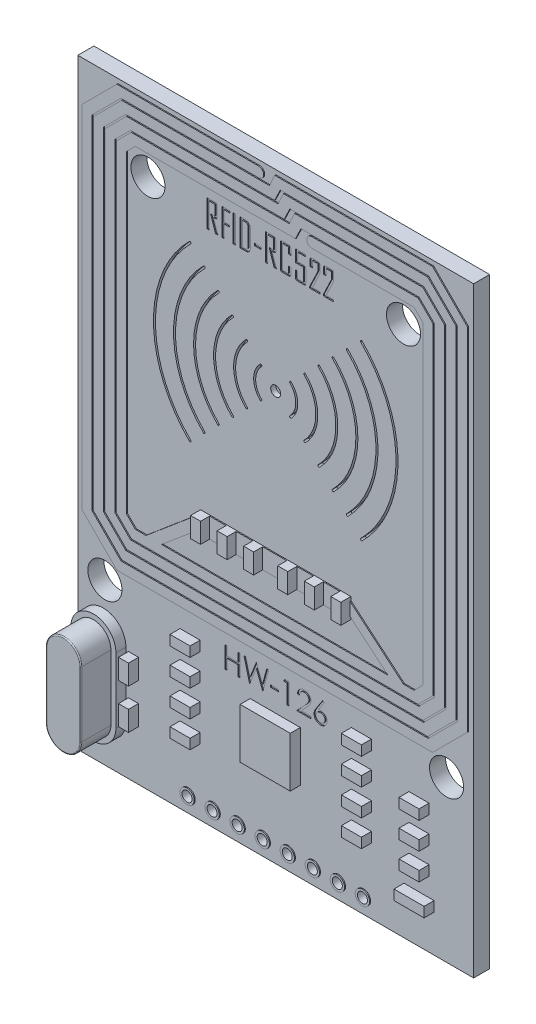
from build123d import *

# Parameters (mm, degrees)
CROQUIS1_W              = 39.5
CROQUIS1_H              = 60
CROQUIS1_R              = 1.7
SALIENTE_EXTRUIR1_DEPTH = 1.6
SALIENTE_EXTRUIR2_DEPTH = 1
SALIENTE_EXTRUIR3_DEPTH = 3
REDONDEO1_R             = 0.1
SALIENTE_EXTRUIR4_DEPTH = 0.1
CROQUIS5_R              = 0.5
CORTAR_EXTRUIR1_DEPTH   = 0.5
CROQUIS7_W              = 1
CROQUIS7_H              = 2
SALIENTE_EXTRUIR5_DEPTH = 1
CROQUIS8_W              = 5
CROQUIS8_H              = 5
CROQUIS8_W_2            = 2
CROQUIS8_H_2            = 1
CROQUIS8_W_3            = 1
CROQUIS8_H_3            = 2
CROQUIS8_W_4            = 3
SALIENTE_EXTRUIR6_DEPTH = 1
CROQUIS9_R              = 0.5
CORTAR_EXTRUIR3_DEPTH   = 2.6
CROQUIS10_R             = 0.717542526
CROQUIS10_R_2           = 0.5
SALIENTE_EXTRUIR7_DEPTH = 0.1
MATRIZL3_COUNT          = 8
MATRIZL3_PITCH          = 2.5
CROQUIS11_W             = 0.227355548
CROQUIS11_H             = 2.695787218
CROQUIS11_W_2           = 0.649587282
CROQUIS11_H_2           = 0.227355549
CORTAR_EXTRUIR4_DEPTH   = 0.1
CROQUIS12_W             = 0.814102565
CROQUIS12_H             = 0.217094017
CORTAR_EXTRUIR5_DEPTH   = 0.1


with BuildPart() as part:
    # Croquis1 → Saliente-Extruir1 (new body)
    with BuildSketch(Plane.XY):
        Rectangle(CROQUIS1_W, CROQUIS1_H)
        with Locations((-12.75, 23)):
            Circle(CROQUIS1_R, mode=Mode.SUBTRACT)
        with Locations((12.75, 23)):
            Circle(CROQUIS1_R, mode=Mode.SUBTRACT)
        with Locations((-17.05, -14)):
            Circle(CROQUIS1_R, mode=Mode.SUBTRACT)
        with Locations((17.05, -14)):
            Circle(CROQUIS1_R, mode=Mode.SUBTRACT)
    extrude(amount=SALIENTE_EXTRUIR1_DEPTH)

    # Croquis2 → Saliente-Extruir2 (add)
    with BuildSketch(Plane.XY.offset(1.6)):
        with BuildLine():
            Line((-19.45, -25.25), (-19.45, -18.75))
            ThreePointArc((-19.45, -18.75), (-17.2, -16.5), (-14.95, -18.75))
            Line((-14.95, -18.75), (-14.95, -25.25))
            ThreePointArc((-14.95, -25.25), (-17.2, -27.5), (-19.45, -25.25))
        make_face()
    extrude(amount=SALIENTE_EXTRUIR2_DEPTH)

    # Croquis3 → Saliente-Extruir3 (add)
    with BuildSketch(Plane.XY.offset(2.6)):
        with BuildLine():
            Line((-18.95, -18.75), (-18.95, -25.25))
            ThreePointArc((-18.95, -25.25), (-17.2, -27), (-15.45, -25.25))
            Line((-15.45, -25.25), (-15.45, -18.75))
            ThreePointArc((-15.45, -18.75), (-17.2, -17), (-18.95, -18.75))
        make_face()
    extrude(amount=SALIENTE_EXTRUIR3_DEPTH)

    # Redondeo1
    redondeo1_edges = [part.edges().sort_by_distance(p)[0] for p in [
        (-15.45, -22, 5.6),
        (-17.2, -17, 5.6),
        (-18.95, -22, 5.6),
        (-17.2, -27, 5.6),
    ]]
    fillet(redondeo1_edges, radius=REDONDEO1_R)

    # Croquis4 → Saliente-Extruir4 (add)
    with BuildSketch(Plane.XY.offset(1.6)):
        with BuildLine():
            Line((-19.25, 26.047780476), (-19.25, -8.952219524))
            Line((-19.25, -8.952219524), (-15.75, -12.452219524))
            Line((-15.75, -12.452219524), (15.75, -12.452219524))
            Line((15.75, -12.452219524), (19.25, -8.952219524))
            Line((19.25, -8.952219524), (19.25, 26.047780476))
            Line((19.25, 26.047780476), (15.75, 29.547780476))
            Line((15.75, 29.547780476), (0, 29.547780476))
            Line((0, 29.547780476), (-0.534883721, 28.397780476))
            Line((-0.534883721, 28.397780476), (-15.273654403, 28.397780476))
            Line((-15.273654403, 28.397780476), (-18.1, 25.571434879))
            Line((-18.1, 25.571434879), (-18.1, -8.475873927))
            Line((-18.1, -8.475873927), (-15.273654403, -11.302219524))
            Line((-15.273654403, -11.302219524), (15.273654403, -11.302219524))
            Line((15.273654403, -11.302219524), (18.1, -8.475873927))
            Line((18.1, -8.475873927), (18.1, 25.571434879))
            Line((18.1, 25.571434879), (15.273654403, 28.397780476))
            Line((15.273654403, 28.397780476), (0.882271335, 28.397780476))
            Line((0.882271335, 28.397780476), (0.32962331, 27.247780476))
            Line((0.32962331, 27.247780476), (-14.797308807, 27.247780476))
            Line((-14.797308807, 27.247780476), (-16.95, 25.095089283))
            Line((-16.95, 25.095089283), (-16.95, -7.999528331))
            Line((-16.95, -7.999528331), (-14.797308807, -10.152219524))
            Line((-14.797308807, -10.152219524), (14.797308807, -10.152219524))
            Line((14.797308807, -10.152219524), (16.95, -7.999528331))
            Line((16.95, -7.999528331), (16.95, 25.095089283))
            Line((16.95, 25.095089283), (14.797308807, 27.247780476))
            Line((14.797308807, 27.247780476), (1.994267695, 27.247780476))
            Line((1.994267695, 27.247780476), (1.43910124, 26.097780476))
            Line((1.43910124, 26.097780476), (-14.32096321, 26.097780476))
            Line((-14.32096321, 26.097780476), (-15.8, 24.618743686))
            Line((-15.8, 24.618743686), (-15.8, -7.523182734))
            Line((-15.8, -7.523182734), (-14.32096321, -9.002219524))
            Line((-14.32096321, -9.002219524), (14.32096321, -9.002219524))
            Line((14.32096321, -9.002219524), (15.8, -7.523182734))
            Line((15.8, -7.523182734), (15.8, 24.618743686))
            Line((15.8, 24.618743686), (14.32096321, 26.097780476))
            Line((14.32096321, 26.097780476), (3.697336559, 26.097780476))
            ThreePointArc((3.697336559, 26.097780476), (3.197336559, 25.597780476), (3.697336559, 25.097780476))
            Line((3.697336559, 25.097780476), (13.906749647, 25.097780476))
            Line((13.906749647, 25.097780476), (14.8, 24.204530123))
            Line((14.8, 24.204530123), (14.8, -7.108969171))
            Line((14.8, -7.108969171), (13.906749647, -8.002219524))
            Line((13.906749647, -8.002219524), (12.844513319, -8.002219524))
            Line((12.844513319, -8.002219524), (7.5, -3.498354667))
            Line((7.5, -3.498354667), (7.5, -3.152219524))
            Line((7.5, -3.152219524), (-7.5, -3.152219524))
            Line((-7.5, -3.152219524), (-7.5, -3.498354667))
            Line((-7.5, -3.498354667), (-12.844513319, -8.002219524))
            Line((-12.844513319, -8.002219524), (-13.906749647, -8.002219524))
            Line((-13.906749647, -8.002219524), (-14.8, -7.108969171))
            Line((-14.8, -7.108969171), (-14.8, 24.204530123))
            Line((-14.8, 24.204530123), (-13.906749647, 25.097780476))
            Line((-13.906749647, 25.097780476), (2.066776044, 25.097780476))
            Line((2.066776044, 25.097780476), (2.621942499, 26.247780476))
            Line((2.621942499, 26.247780476), (14.383095244, 26.247780476))
            Line((14.383095244, 26.247780476), (15.95, 24.68087572))
            Line((15.95, 24.68087572), (15.95, -7.585314768))
            Line((15.95, -7.585314768), (14.383095244, -9.152219524))
            Line((14.383095244, -9.152219524), (-14.383095244, -9.152219524))
            Line((-14.383095244, -9.152219524), (-15.95, -7.585314768))
            Line((-15.95, -7.585314768), (-15.95, 24.68087572))
            Line((-15.95, 24.68087572), (-14.383095244, 26.247780476))
            Line((-14.383095244, 26.247780476), (0.95853774, 26.247780476))
            Line((0.95853774, 26.247780476), (1.511185765, 27.397780476))
            Line((1.511185765, 27.397780476), (14.859440841, 27.397780476))
            Line((14.859440841, 27.397780476), (17.1, 25.157221317))
            Line((17.1, 25.157221317), (17.1, -8.061660365))
            Line((17.1, -8.061660365), (14.859440841, -10.302219524))
            Line((14.859440841, -10.302219524), (-14.859440841, -10.302219524))
            Line((-14.859440841, -10.302219524), (-17.1, -8.061660365))
            Line((-17.1, -8.061660365), (-17.1, 25.157221317))
            Line((-17.1, 25.157221317), (-14.859440841, 27.397780476))
            Line((-14.859440841, 27.397780476), (0, 27.397780476))
            Line((0, 27.397780476), (0.552648025, 28.547780476))
            Line((0.552648025, 28.547780476), (15.335786438, 28.547780476))
            Line((15.335786438, 28.547780476), (18.25, 25.633566914))
            Line((18.25, 25.633566914), (18.25, -8.538005962))
            Line((18.25, -8.538005962), (15.335786438, -11.452219524))
            Line((15.335786438, -11.452219524), (-15.335786438, -11.452219524))
            Line((-15.335786438, -11.452219524), (-18.25, -8.538005962))
            Line((-18.25, -8.538005962), (-18.25, 25.633566914))
            Line((-18.25, 25.633566914), (-15.335786438, 28.547780476))
            Line((-15.335786438, 28.547780476), (-1.600959239, 28.547780476))
            ThreePointArc((-1.600959239, 28.547780476), (-1.100959239, 29.047780476), (-1.600959239, 29.547780476))
            Line((-1.600959239, 29.547780476), (-15.75, 29.547780476))
            Line((-15.75, 29.547780476), (-19.25, 26.047780476))
        make_face()
        Polygon((-11.292695249, -8.002219524), (-7.5, -4.806084381), (-7.5, -5.152219524), (7.5, -5.152219524), (7.5, -4.806084381), (11.292695249, -8.002219524), align=None, mode=Mode.SUBTRACT)
    extrude(amount=SALIENTE_EXTRUIR4_DEPTH)

    # Croquis5 → Cortar-Extruir1 (cut)
    with BuildSketch(Plane.XY.offset(1.6)):
        with Locations((0, 10.847780476)):
            Circle(CROQUIS5_R)
        with BuildLine():
            ThreePointArc((-1.414213562, 12.261994038), (-2, 10.847780476), (-1.414213562, 9.433566914))
            ThreePointArc((-1.414213562, 9.433566914), (-1.414213562, 9.292145557), (-1.555634919, 9.292145557))
            ThreePointArc((-1.555634919, 9.292145557), (-2.2, 10.847780476), (-1.555634919, 12.403415395))
            ThreePointArc((-1.555634919, 12.403415395), (-1.414213562, 12.403415395), (-1.414213562, 12.261994038))
        make_face()
        with BuildLine():
            ThreePointArc((-2.828427125, 13.676207601), (-4, 10.847780476), (-2.828427125, 8.019353351))
            ThreePointArc((-2.828427125, 8.019353351), (-2.828427125, 7.877931995), (-2.969848481, 7.877931995))
            ThreePointArc((-2.969848481, 7.877931995), (-4.2, 10.847780476), (-2.969848481, 13.817628957))
            ThreePointArc((-2.969848481, 13.817628957), (-2.828427125, 13.817628957), (-2.828427125, 13.676207601))
        make_face()
        with BuildLine():
            ThreePointArc((-4.242640687, 15.090421163), (-6, 10.847780476), (-4.242640687, 6.605139789))
            ThreePointArc((-4.242640687, 6.605139789), (-4.242640687, 6.463718433), (-4.384062043, 6.463718433))
            ThreePointArc((-4.384062043, 6.463718433), (-6.2, 10.847780476), (-4.384062043, 15.231842519))
            ThreePointArc((-4.384062043, 15.231842519), (-4.242640687, 15.231842519), (-4.242640687, 15.090421163))
        make_face()
        with BuildLine():
            ThreePointArc((-5.656854249, 16.504634725), (-8, 10.847780476), (-5.656854249, 5.190926227))
            ThreePointArc((-5.656854249, 5.190926227), (-5.656854249, 5.04950487), (-5.798275606, 5.04950487))
            ThreePointArc((-5.798275606, 5.04950487), (-8.2, 10.847780476), (-5.798275606, 16.646056082))
            ThreePointArc((-5.798275606, 16.646056082), (-5.656854249, 16.646056082), (-5.656854249, 16.504634725))
        make_face()
        with BuildLine():
            ThreePointArc((-7.071067812, 17.918848288), (-10, 10.847780476), (-7.071067812, 3.776712664))
            ThreePointArc((-7.071067812, 3.776712664), (-7.071067812, 3.635291308), (-7.212489168, 3.635291308))
            ThreePointArc((-7.212489168, 3.635291308), (-10.2, 10.847780476), (-7.212489168, 18.060269644))
            ThreePointArc((-7.212489168, 18.060269644), (-7.071067812, 18.060269644), (-7.071067812, 17.918848288))
        make_face()
        with BuildLine():
            ThreePointArc((-8.485281374, 19.33306185), (-12, 10.847780476), (-8.485281374, 2.362499102))
            ThreePointArc((-8.485281374, 2.362499102), (-8.485281374, 2.221077746), (-8.62670273, 2.221077746))
            ThreePointArc((-8.62670273, 2.221077746), (-12.2, 10.847780476), (-8.62670273, 19.474483206))
            ThreePointArc((-8.62670273, 19.474483206), (-8.485281374, 19.474483206), (-8.485281374, 19.33306185))
        make_face()
        with BuildLine():
            ThreePointArc((2.828427125, 13.676207601), (2.828427125, 13.817628957), (2.969848481, 13.817628957))
            ThreePointArc((2.969848481, 13.817628957), (4.2, 10.847780476), (2.969848481, 7.877931995))
            ThreePointArc((2.969848481, 7.877931995), (2.828427125, 7.877931995), (2.828427125, 8.019353351))
            ThreePointArc((2.828427125, 8.019353351), (4, 10.847780476), (2.828427125, 13.676207601))
        make_face()
        with BuildLine():
            ThreePointArc((4.242640687, 15.090421163), (4.242640687, 15.231842519), (4.384062043, 15.231842519))
            ThreePointArc((4.384062043, 15.231842519), (6.2, 10.847780476), (4.384062043, 6.463718433))
            ThreePointArc((4.384062043, 6.463718433), (4.242640687, 6.463718433), (4.242640687, 6.605139789))
            ThreePointArc((4.242640687, 6.605139789), (6, 10.847780476), (4.242640687, 15.090421163))
        make_face()
        with BuildLine():
            ThreePointArc((1.414213562, 12.261994038), (1.414213562, 12.403415395), (1.555634919, 12.403415395))
            ThreePointArc((1.555634919, 12.403415395), (2.2, 10.847780476), (1.555634919, 9.292145557))
            ThreePointArc((1.555634919, 9.292145557), (1.414213562, 9.292145557), (1.414213562, 9.433566914))
            ThreePointArc((1.414213562, 9.433566914), (2, 10.847780476), (1.414213562, 12.261994038))
        make_face()
        with BuildLine():
            ThreePointArc((5.656854249, 16.504634725), (5.656854249, 16.646056082), (5.798275606, 16.646056082))
            ThreePointArc((5.798275606, 16.646056082), (8.2, 10.847780476), (5.798275606, 5.04950487))
            ThreePointArc((5.798275606, 5.04950487), (5.656854249, 5.04950487), (5.656854249, 5.190926227))
            ThreePointArc((5.656854249, 5.190926227), (8, 10.847780476), (5.656854249, 16.504634725))
        make_face()
        with BuildLine():
            ThreePointArc((7.071067812, 17.918848288), (7.071067812, 18.060269644), (7.212489168, 18.060269644))
            ThreePointArc((7.212489168, 18.060269644), (10.2, 10.847780476), (7.212489168, 3.635291308))
            ThreePointArc((7.212489168, 3.635291308), (7.071067812, 3.635291308), (7.071067812, 3.776712664))
            ThreePointArc((7.071067812, 3.776712664), (10, 10.847780476), (7.071067812, 17.918848288))
        make_face()
        with BuildLine():
            ThreePointArc((8.62670273, 19.474483206), (8.485281374, 19.474483206), (8.485281374, 19.33306185))
            ThreePointArc((8.485281374, 19.33306185), (12, 10.847780476), (8.485281374, 2.362499102))
            ThreePointArc((8.485281374, 2.362499102), (8.485281374, 2.221077746), (8.62670273, 2.221077746))
            ThreePointArc((8.62670273, 2.221077746), (12.2, 10.847780476), (8.62670273, 19.474483206))
        make_face()
    extrude(amount=-CORTAR_EXTRUIR1_DEPTH, mode=Mode.SUBTRACT)

    # Croquis7 → Saliente-Extruir5 (add)
    with BuildSketch(Plane.XY.offset(1.6)):
        with Locations((-7, -4.152219524)):
            Rectangle(CROQUIS7_W, CROQUIS7_H)
        with Locations((-4.35, -4.152219524)):
            Rectangle(CROQUIS7_W, CROQUIS7_H)
        with Locations((-1.7, -4.152219524)):
            Rectangle(CROQUIS7_W, CROQUIS7_H)
        with Locations((1.7, -4.152219524)):
            Rectangle(CROQUIS7_W, CROQUIS7_H)
        with Locations((4.35, -4.152219524)):
            Rectangle(CROQUIS7_W, CROQUIS7_H)
        with Locations((7, -4.152219524)):
            Rectangle(CROQUIS7_W, CROQUIS7_H)
    extrude(amount=SALIENTE_EXTRUIR5_DEPTH)

    # Croquis8 → Saliente-Extruir6 (add)
    with BuildSketch(Plane.XY.offset(1.6)):
        with Locations((-0.051147358, -19.5)):
            Rectangle(CROQUIS8_W, CROQUIS8_H)
        with Locations((-8.551147358, -14.952219524)):
            Rectangle(CROQUIS8_W_2, CROQUIS8_H_2)
        with Locations((-8.551147358, -17.612219524)):
            Rectangle(CROQUIS8_W_2, CROQUIS8_H_2)
        with Locations((-8.551147358, -20.272219524)):
            Rectangle(CROQUIS8_W_2, CROQUIS8_H_2)
        with Locations((-8.551147358, -22.932219524)):
            Rectangle(CROQUIS8_W_2, CROQUIS8_H_2)
        with Locations((8.551147358, -22.932219524)):
            Rectangle(CROQUIS8_W_2, CROQUIS8_H_2)
        with Locations((8.551147358, -20.272219524)):
            Rectangle(CROQUIS8_W_2, CROQUIS8_H_2)
        with Locations((8.551147358, -17.612219524)):
            Rectangle(CROQUIS8_W_2, CROQUIS8_H_2)
        with Locations((8.551147358, -14.952219524)):
            Rectangle(CROQUIS8_W_2, CROQUIS8_H_2)
        with Locations((-14.193547231, -24.003996479)):
            Rectangle(CROQUIS8_W_3, CROQUIS8_H_3)
        with Locations((-14.193547231, -20.003996479)):
            Rectangle(CROQUIS8_W_3, CROQUIS8_H_3)
        with Locations((14.301080086, -20.272219524)):
            Rectangle(CROQUIS8_W_2, CROQUIS8_H_2)
        with Locations((14.301080086, -17.612219524)):
            Rectangle(CROQUIS8_W_2, CROQUIS8_H_2)
        with Locations((14.301080086, -22.932219524)):
            Rectangle(CROQUIS8_W_2, CROQUIS8_H_2)
        with Locations((14.301080086, -25.782053299)):
            Rectangle(CROQUIS8_W_4, CROQUIS8_H_2)
    extrude(amount=SALIENTE_EXTRUIR6_DEPTH)

    # Croquis9 → Cortar-Extruir3 (cut, through all)
    with BuildSketch(Plane.XY.offset(1.6)):
        with Locations((-8.75, -28.5)):
            Circle(CROQUIS9_R)
        with Locations((-6.25, -28.5)):
            Circle(CROQUIS9_R)
        with Locations((-3.75, -28.5)):
            Circle(CROQUIS9_R)
        with Locations((-1.25, -28.5)):
            Circle(CROQUIS9_R)
        with Locations((1.25, -28.5)):
            Circle(CROQUIS9_R)
        with Locations((3.75, -28.5)):
            Circle(CROQUIS9_R)
        with Locations((6.25, -28.5)):
            Circle(CROQUIS9_R)
        with Locations((8.75, -28.5)):
            Circle(CROQUIS9_R)
    extrude(amount=-CORTAR_EXTRUIR3_DEPTH, mode=Mode.SUBTRACT)

    # Croquis10 → Saliente-Extruir7 (add)
    with BuildSketch(Plane.XY.offset(1.6)):
        with Locations((-8.75, -28.5)):
            Circle(CROQUIS10_R)
        with Locations((-8.75, -28.5)):
            Circle(CROQUIS10_R_2, mode=Mode.SUBTRACT)
    saliente_extruir7 = extrude(amount=SALIENTE_EXTRUIR7_DEPTH)

    # MatrizL3: Saliente-Extruir7 ×8
    with Locations(*[(i * MATRIZL3_PITCH, 0, 0) for i in range(1, MATRIZL3_COUNT)]):
        add(saliente_extruir7)

    # Croquis11 → Cortar-Extruir4 (cut)
    with BuildSketch(Plane.XY.offset(1.6)):
        with BuildLine():
            Line((-5.772253363, 21.446606184), (-5.999608911, 21.446606184))
            Line((-5.999608911, 21.446606184), (-6.486799372, 22.892445375))
            Line((-6.486799372, 22.892445375), (-6.456857458, 22.940656931))
            Line((-6.456857458, 22.940656931), (-6.064567639, 22.940656931))
            Line((-6.064567639, 22.940656931), (-6.064567639, 23.947517218))
            Line((-6.064567639, 23.947517218), (-6.649196193, 23.947517218))
            Line((-6.649196193, 23.947517218), (-6.649196193, 21.446606184))
            Line((-6.649196193, 21.446606184), (-6.876551741, 21.446606184))
            Line((-6.876551741, 21.446606184), (-6.876551741, 24.142393402))
            Line((-6.876551741, 24.142393402), (-6.036148196, 24.142393402))
            add(Edge.make_bspline(
                [(-6.036148196, 24.142393402), (-6.022043733, 24.141730622), (-5.994959103, 24.140457892), (-5.956115522, 24.130090376), (-5.921730204, 24.112102711), (-5.892247347, 24.087358146), (-5.867502781, 24.057875289), (-5.849515117, 24.023489971), (-5.839147601, 23.984646389), (-5.837874871, 23.95756176), (-5.837212091, 23.943457297)],
                knots=[0, 0, 0, 0, 4.2271e-05, 8.1173e-05, 0.000119535, 0.000157742, 0.000195948, 0.00023431, 0.000273212, 0.000315483, 0.000315483, 0.000315483, 0.000315483], degree=3))
            Line((-5.837212091, 23.943457297), (-5.837212091, 22.944716852))
            add(Edge.make_bspline(
                [(-5.837212091, 22.944716852), (-5.837743488, 22.929069909), (-5.838747191, 22.899515937), (-5.850286283, 22.858130683), (-5.869049438, 22.822594249), (-5.896555034, 22.794021996), (-5.931009616, 22.771572781), (-5.973316857, 22.756934185), (-6.022494226, 22.747018373), (-6.05791182, 22.746210425), (-6.076747401, 22.745780747)],
                knots=[0, 0, 0, 0, 4.6824e-05, 8.8441e-05, 0.000127728, 0.00016614, 0.000206116, 0.000249952, 0.000299616, 0.00035603, 0.00035603, 0.00035603, 0.00035603], degree=3))
            add(Edge.make_bspline(
                [(-6.076747401, 22.745780747), (-6.086561169, 22.745881634), (-6.109757101, 22.746120091), (-6.145937227, 22.748280465), (-6.181267578, 22.750482288), (-6.203279409, 22.750747569), (-6.212247248, 22.750855648)],
                knots=[0, 0, 0, 0, 2.9439e-05, 6.9582e-05, 0.000108711, 0.000135613, 0.000135613, 0.000135613, 0.000135613], degree=3))
            add(Edge.make_bspline(
                [(-6.212247248, 22.750855648), (-6.138741374, 22.533849081), (-5.991541278, 22.099279903), (-5.84541166, 21.664349593), (-5.772253363, 21.446606184)],
                knots=[0, 0, 0, 0, 0.000687353, 0.001376467, 0.001376467, 0.001376467, 0.001376467], degree=3))
        make_face()
        Polygon((-4.570516892, 23.947517218), (-5.155145445, 23.947517218), (-5.155145445, 22.908177567), (-4.63547562, 22.908177567), (-4.63547562, 22.713301383), (-5.155145445, 22.713301383), (-5.155145445, 21.446606184), (-5.382500994, 21.446606184), (-5.382500994, 24.142393402), (-4.570516892, 24.142393402), align=None)
        with Locations((-4.132045477, 22.794499793)):
            Rectangle(CROQUIS11_W, CROQUIS11_H)
        with BuildLine():
            add(Edge.make_bspline(
                [(-2.524316956, 21.934304135), (-2.524696482, 21.917537148), (-2.525446595, 21.884398092), (-2.531692345, 21.835834682), (-2.541591222, 21.789137194), (-2.556855052, 21.744903974), (-2.574567019, 21.701968808), (-2.598148947, 21.661886536), (-2.624138571, 21.622901949), (-2.655270001, 21.587266801), (-2.689003832, 21.554459587), (-2.724867521, 21.525218214), (-2.763457961, 21.501342365), (-2.803843667, 21.481301072), (-2.846516753, 21.465524152), (-2.891444593, 21.454410172), (-2.938388117, 21.447609119), (-2.970377494, 21.446944213), (-2.986640403, 21.446606184)],
                knots=[0, 0, 0, 0, 5.0283e-05, 9.9381e-05, 0.000146665, 0.000193204, 0.000239584, 0.000285723, 0.000332457, 0.00037996, 0.000427334, 0.000473541, 0.000518459, 0.00056317, 0.000608609, 0.000654643, 0.000701796, 0.000750557, 0.000750557, 0.000750557, 0.000750557], degree=3))
            Line((-2.986640403, 21.446606184), (-3.563656606, 21.446606184))
            Line((-3.563656606, 21.446606184), (-3.563656606, 24.142393402))
            Line((-3.563656606, 24.142393402), (-2.986640403, 24.142393402))
            add(Edge.make_bspline(
                [(-2.986640403, 24.142393402), (-2.970210971, 24.142047489), (-2.937889964, 24.141366988), (-2.890570775, 24.134699464), (-2.845627389, 24.123301612), (-2.802470166, 24.108335742), (-2.76218074, 24.087656541), (-2.723345562, 24.063798083), (-2.68751755, 24.034675736), (-2.654231273, 24.001723372), (-2.623653197, 23.965940585), (-2.59760834, 23.927134011), (-2.57410992, 23.887011559), (-2.556198055, 23.844200693), (-2.541749603, 23.799755047), (-2.531644909, 23.753180516), (-2.525458978, 23.704597419), (-2.524700642, 23.671461069), (-2.524316956, 23.654695451)],
                knots=[0, 0, 0, 0, 4.9268e-05, 9.6924e-05, 0.000142957, 0.000188224, 0.000233615, 0.000278533, 0.00032474, 0.00037175, 0.000418925, 0.000465658, 0.000511798, 0.000558177, 0.000604559, 0.000651843, 0.000700941, 0.000751223, 0.000751223, 0.000751223, 0.000751223], degree=3))
            Line((-2.524316956, 23.654695451), (-2.524316956, 21.934304135))
        make_face()
        with BuildLine():
            Line((-2.751672504, 21.945468917), (-2.751672504, 23.64657561))
            add(Edge.make_bspline(
                [(-2.751672504, 23.64657561), (-2.752343219, 23.668168348), (-2.753628509, 23.709546505), (-2.769168559, 23.76806875), (-2.792822049, 23.820649018), (-2.827389933, 23.865287846), (-2.868701822, 23.902095577), (-2.916999381, 23.928793424), (-2.971072338, 23.944934946), (-3.009195796, 23.946641404), (-3.028762079, 23.947517218)],
                knots=[0, 0, 0, 0, 6.4613e-05, 0.000123818, 0.000180352, 0.000236482, 0.000291861, 0.000345244, 0.000400805, 0.000459386, 0.000459386, 0.000459386, 0.000459386], degree=3))
            Line((-3.028762079, 23.947517218), (-3.336301057, 23.947517218))
            Line((-3.336301057, 23.947517218), (-3.336301057, 21.641482369))
            Line((-3.336301057, 21.641482369), (-3.04144933, 21.641482369))
            add(Edge.make_bspline(
                [(-3.04144933, 21.641482369), (-3.020875455, 21.642370506), (-2.981144247, 21.644085632), (-2.924644065, 21.659772582), (-2.874206759, 21.685515898), (-2.830948005, 21.721610873), (-2.794493462, 21.765855519), (-2.769962669, 21.819614663), (-2.754130513, 21.880116241), (-2.752516478, 21.923029635), (-2.751672504, 21.945468917)],
                knots=[0, 0, 0, 0, 6.1616e-05, 0.000118989, 0.000174371, 0.000230252, 0.000286921, 0.000344806, 0.000406103, 0.000473284, 0.000473284, 0.000473284, 0.000473284], degree=3))
        make_face(mode=Mode.SUBTRACT)
        with Locations((-1.777291582, 22.469706153)):
            Rectangle(CROQUIS11_W_2, CROQUIS11_H_2)
        with BuildLine():
            Line((0.07403217, 21.446606184), (-0.153323378, 21.446606184))
            Line((-0.153323378, 21.446606184), (-0.640513839, 22.892445375))
            Line((-0.640513839, 22.892445375), (-0.610571926, 22.940656931))
            Line((-0.610571926, 22.940656931), (-0.218282106, 22.940656931))
            Line((-0.218282106, 22.940656931), (-0.218282106, 23.947517218))
            Line((-0.218282106, 23.947517218), (-0.80291066, 23.947517218))
            Line((-0.80291066, 23.947517218), (-0.80291066, 21.446606184))
            Line((-0.80291066, 21.446606184), (-1.030266208, 21.446606184))
            Line((-1.030266208, 21.446606184), (-1.030266208, 24.142393402))
            Line((-1.030266208, 24.142393402), (-0.189862663, 24.142393402))
            add(Edge.make_bspline(
                [(-0.189862663, 24.142393402), (-0.1757582, 24.141730622), (-0.148673571, 24.140457892), (-0.109829989, 24.130090376), (-0.075444671, 24.112102711), (-0.045961814, 24.087358146), (-0.021217249, 24.057875289), (-0.003229584, 24.023489971), (0.007137932, 23.984646389), (0.008410662, 23.95756176), (0.009073442, 23.943457297)],
                knots=[0, 0, 0, 0, 4.2271e-05, 8.1173e-05, 0.000119535, 0.000157742, 0.000195948, 0.00023431, 0.000273212, 0.000315483, 0.000315483, 0.000315483, 0.000315483], degree=3))
            Line((0.009073442, 23.943457297), (0.009073442, 22.944716852))
            add(Edge.make_bspline(
                [(0.009073442, 22.944716852), (0.008542045, 22.929069909), (0.007538342, 22.899515937), (-0.00400075, 22.858130683), (-0.022763905, 22.822594249), (-0.050269501, 22.794021996), (-0.084724084, 22.771572781), (-0.127031324, 22.756934185), (-0.176208693, 22.747018373), (-0.211626287, 22.746210425), (-0.230461868, 22.745780747)],
                knots=[0, 0, 0, 0, 4.6824e-05, 8.8441e-05, 0.000127728, 0.00016614, 0.000206116, 0.000249952, 0.000299616, 0.00035603, 0.00035603, 0.00035603, 0.00035603], degree=3))
            add(Edge.make_bspline(
                [(-0.230461868, 22.745780747), (-0.240275636, 22.745881634), (-0.263471568, 22.746120091), (-0.299651694, 22.748280465), (-0.334982045, 22.750482288), (-0.356993876, 22.750747569), (-0.365961715, 22.750855648)],
                knots=[0, 0, 0, 0, 2.9439e-05, 6.9582e-05, 0.000108711, 0.000135613, 0.000135613, 0.000135613, 0.000135613], degree=3))
            add(Edge.make_bspline(
                [(-0.365961715, 22.750855648), (-0.292455841, 22.533849081), (-0.145255745, 22.099279903), (0.000873873, 21.664349593), (0.07403217, 21.446606184)],
                knots=[0, 0, 0, 0, 0.000687353, 0.001376467, 0.001376467, 0.001376467, 0.001376467], degree=3))
        make_face()
        with BuildLine():
            add(Edge.make_bspline(
                [(1.503124189, 21.645542289), (1.502534016, 21.631414446), (1.501398821, 21.604239638), (1.49004687, 21.565744408), (1.472863768, 21.530765577), (1.447647438, 21.501191305), (1.417789046, 21.476432651), (1.3830716, 21.459008842), (1.344707066, 21.44859986), (1.317956728, 21.44728365), (1.304188084, 21.446606184)],
                knots=[0, 0, 0, 0, 4.2271e-05, 8.1308e-05, 0.000119438, 0.000158359, 0.000196959, 0.000235088, 0.00027399, 0.00031525, 0.00031525, 0.00031525, 0.00031525], degree=3))
            Line((1.304188084, 21.446606184), (0.662720644, 21.446606184))
            add(Edge.make_bspline(
                [(0.662720644, 21.446606184), (0.648611481, 21.447258181), (0.621517826, 21.448510202), (0.582812894, 21.459002465), (0.548138363, 21.476458491), (0.518202161, 21.501023806), (0.493636846, 21.530960008), (0.47618082, 21.565634539), (0.465688557, 21.604339471), (0.464436536, 21.631433126), (0.463784539, 21.645542289)],
                knots=[0, 0, 0, 0, 4.2271e-05, 8.1173e-05, 0.000119302, 0.000157902, 0.000196501, 0.00023463, 0.000273532, 0.000315803, 0.000315803, 0.000315803, 0.000315803], degree=3))
            Line((0.463784539, 21.645542289), (0.463784539, 23.943457297))
            add(Edge.make_bspline(
                [(0.463784539, 23.943457297), (0.464434162, 23.957568227), (0.465681624, 23.984665275), (0.476205786, 24.023346465), (0.493485741, 24.057990314), (0.518368486, 24.087522769), (0.548254667, 24.11194932), (0.582669423, 24.130115237), (0.621536689, 24.140451006), (0.648617941, 24.141728263), (0.662720644, 24.142393402)],
                knots=[0, 0, 0, 0, 4.2271e-05, 8.1173e-05, 0.000119302, 0.000157509, 0.000196108, 0.00023447, 0.000273372, 0.000315643, 0.000315643, 0.000315643, 0.000315643], degree=3))
            Line((0.662720644, 24.142393402), (1.304188084, 24.142393402))
            add(Edge.make_bspline(
                [(1.304188084, 24.142393402), (1.317950491, 24.141703257), (1.344688709, 24.140362414), (1.383215112, 24.130108852), (1.417672929, 24.111975725), (1.447482608, 24.087353733), (1.473013322, 24.058186656), (1.490021868, 24.023236185), (1.501405745, 23.984765209), (1.502536384, 23.957586939), (1.503124189, 23.943457297)],
                knots=[0, 0, 0, 0, 4.126e-05, 8.0162e-05, 0.000118523, 0.000157123, 0.000195655, 0.000233784, 0.000272822, 0.000315093, 0.000315093, 0.000315093, 0.000315093], degree=3))
            Line((1.503124189, 23.943457297), (1.503124189, 23.3304093))
            Line((1.503124189, 23.3304093), (1.275768641, 23.3304093))
            Line((1.275768641, 23.3304093), (1.275768641, 23.947517218))
            Line((1.275768641, 23.947517218), (0.691140087, 23.947517218))
            Line((0.691140087, 23.947517218), (0.691140087, 21.641482369))
            Line((0.691140087, 21.641482369), (1.275768641, 21.641482369))
            Line((1.275768641, 21.641482369), (1.275768641, 22.29106965))
            Line((1.275768641, 22.29106965), (1.503124189, 22.29106965))
            Line((1.503124189, 22.29106965), (1.503124189, 21.645542289))
        make_face()
        with BuildLine():
            add(Edge.make_bspline(
                [(2.997174937, 21.645542289), (2.996523215, 21.632106501), (2.995247291, 21.605802278), (2.984225314, 21.56784435), (2.965592448, 21.533378218), (2.940280456, 21.503116706), (2.909828019, 21.478378183), (2.875851648, 21.459407996), (2.837963219, 21.448561793), (2.811669337, 21.44726736), (2.798238832, 21.446606184)],
                knots=[0, 0, 0, 0, 4.0249e-05, 7.8798e-05, 0.000117397, 0.000157034, 0.000196347, 0.0002345, 0.000273049, 0.000313298, 0.000313298, 0.000313298, 0.000313298], degree=3))
            Line((2.798238832, 21.446606184), (2.156771391, 21.446606184))
            add(Edge.make_bspline(
                [(2.156771391, 21.446606184), (2.143166415, 21.447246326), (2.116692595, 21.448491974), (2.078547634, 21.45953127), (2.044264277, 21.478231108), (2.013735182, 21.502994291), (1.988856456, 21.533410516), (1.970875496, 21.567974129), (1.959733192, 21.605788328), (1.958476953, 21.632101785), (1.957835286, 21.645542289)],
                knots=[0, 0, 0, 0, 4.0754e-05, 7.9304e-05, 0.000117903, 0.000157216, 0.000196529, 0.000234891, 0.00027344, 0.000313689, 0.000313689, 0.000313689, 0.000313689], degree=3))
            Line((1.957835286, 21.645542289), (1.957835286, 22.323549014))
            Line((1.957835286, 22.323549014), (2.185190835, 22.323549014))
            Line((2.185190835, 22.323549014), (2.185190835, 21.641482369))
            Line((2.185190835, 21.641482369), (2.769819388, 21.641482369))
            Line((2.769819388, 21.641482369), (2.769819388, 22.940656931))
            Line((2.769819388, 22.940656931), (1.957835286, 22.940656931))
            Line((1.957835286, 22.940656931), (1.99031465, 24.142393402))
            Line((1.99031465, 24.142393402), (2.964695572, 24.142393402))
            Line((2.964695572, 24.142393402), (2.964695572, 23.947517218))
            Line((2.964695572, 23.947517218), (2.214625258, 23.947517218))
            Line((2.214625258, 23.947517218), (2.185190835, 23.135533116))
            Line((2.185190835, 23.135533116), (2.798238832, 23.135533116))
            add(Edge.make_bspline(
                [(2.798238832, 23.135533116), (2.811671102, 23.134850619), (2.837922649, 23.133516773), (2.875515381, 23.123063225), (2.90994856, 23.1060051), (2.940005213, 23.082063593), (2.965865846, 23.053276192), (2.984285064, 23.0192153), (2.995338982, 22.981087024), (2.99654925, 22.954435368), (2.997174937, 22.940656931)],
                knots=[0, 0, 0, 0, 4.0249e-05, 7.8661e-05, 0.000116109, 0.000154788, 0.000193267, 0.00023142, 0.000269969, 0.000311229, 0.000311229, 0.000311229, 0.000311229], degree=3))
            Line((2.997174937, 22.940656931), (2.997174937, 21.645542289))
        make_face()
        with BuildLine():
            Line((4.426266956, 21.446606184), (3.386927305, 21.446606184))
            Line((3.386927305, 21.446606184), (3.386927305, 21.57652364))
            Line((3.386927305, 21.57652364), (4.198911407, 23.280675274))
            Line((4.198911407, 23.280675274), (4.198911407, 23.947517218))
            Line((4.198911407, 23.947517218), (3.646762218, 23.947517218))
            Line((3.646762218, 23.947517218), (3.646762218, 23.3304093))
            Line((3.646762218, 23.3304093), (3.419406669, 23.3304093))
            Line((3.419406669, 23.3304093), (3.419406669, 23.943457297))
            add(Edge.make_bspline(
                [(3.419406669, 23.943457297), (3.420107072, 23.955877415), (3.421493602, 23.980464497), (3.432184812, 24.01636045), (3.449739124, 24.050249461), (3.473981839, 24.081377653), (3.503608657, 24.108255801), (3.537935414, 24.128675028), (3.577052976, 24.140043106), (3.604230668, 24.141590113), (3.618342774, 24.142393402)],
                knots=[0, 0, 0, 0, 3.7217e-05, 7.3675e-05, 0.000111352, 0.000151144, 0.000191393, 0.000230736, 0.000269915, 0.000312231, 0.000312231, 0.000312231, 0.000312231], degree=3))
            Line((3.618342774, 24.142393402), (4.227330851, 24.142393402))
            add(Edge.make_bspline(
                [(4.227330851, 24.142393402), (4.240776244, 24.141781643), (4.267147166, 24.14058178), (4.304947562, 24.128979572), (4.339299306, 24.109670344), (4.369092711, 24.08327953), (4.394449676, 24.05277726), (4.413219015, 24.018783922), (4.424302209, 23.981861291), (4.42560545, 23.95638745), (4.426266956, 23.943457297)],
                knots=[0, 0, 0, 0, 4.0249e-05, 7.8941e-05, 0.00011734, 0.000157634, 0.000197661, 0.000235814, 0.000273389, 0.000312121, 0.000312121, 0.000312121, 0.000312121], degree=3))
            Line((4.426266956, 23.943457297), (4.426266956, 23.352738863))
            add(Edge.make_bspline(
                [(4.426266956, 23.352738863), (4.425341508, 23.334928907), (4.423412961, 23.297814585), (4.411639289, 23.240550062), (4.392134741, 23.179933701), (4.374220741, 23.13943767), (4.364860658, 23.118278454)],
                knots=[0, 0, 0, 0, 5.3441e-05, 0.000111366, 0.000174762, 0.000244132, 0.000244132, 0.000244132, 0.000244132], degree=3))
            Line((4.364860658, 23.118278454), (3.679241582, 21.641482369))
            Line((3.679241582, 21.641482369), (4.426266956, 21.641482369))
            Line((4.426266956, 21.641482369), (4.426266956, 21.446606184))
        make_face()
        with BuildLine():
            Line((5.790400247, 21.446606184), (4.751060596, 21.446606184))
            Line((4.751060596, 21.446606184), (4.751060596, 21.57652364))
            Line((4.751060596, 21.57652364), (5.563044698, 23.280675274))
            Line((5.563044698, 23.280675274), (5.563044698, 23.947517218))
            Line((5.563044698, 23.947517218), (5.010895509, 23.947517218))
            Line((5.010895509, 23.947517218), (5.010895509, 23.3304093))
            Line((5.010895509, 23.3304093), (4.78353996, 23.3304093))
            Line((4.78353996, 23.3304093), (4.78353996, 23.943457297))
            add(Edge.make_bspline(
                [(4.78353996, 23.943457297), (4.784240363, 23.955877415), (4.785626893, 23.980464497), (4.796318103, 24.01636045), (4.813872415, 24.050249461), (4.83811513, 24.081377653), (4.867741948, 24.108255801), (4.902068705, 24.128675028), (4.941186267, 24.140043106), (4.968363959, 24.141590113), (4.982476065, 24.142393402)],
                knots=[0, 0, 0, 0, 3.7217e-05, 7.3675e-05, 0.000111352, 0.000151144, 0.000191393, 0.000230736, 0.000269915, 0.000312231, 0.000312231, 0.000312231, 0.000312231], degree=3))
            Line((4.982476065, 24.142393402), (5.591464142, 24.142393402))
            add(Edge.make_bspline(
                [(5.591464142, 24.142393402), (5.604909535, 24.141781643), (5.631280457, 24.14058178), (5.669080853, 24.128979572), (5.703432597, 24.109670344), (5.733226002, 24.08327953), (5.758582967, 24.05277726), (5.777352306, 24.018783922), (5.7884355, 23.981861291), (5.789738741, 23.95638745), (5.790400247, 23.943457297)],
                knots=[0, 0, 0, 0, 4.0249e-05, 7.8941e-05, 0.00011734, 0.000157634, 0.000197661, 0.000235814, 0.000273389, 0.000312121, 0.000312121, 0.000312121, 0.000312121], degree=3))
            Line((5.790400247, 23.943457297), (5.790400247, 23.352738863))
            add(Edge.make_bspline(
                [(5.790400247, 23.352738863), (5.789474799, 23.334928907), (5.787546252, 23.297814585), (5.77577258, 23.240550062), (5.756268032, 23.179933701), (5.738354032, 23.13943767), (5.728993949, 23.118278454)],
                knots=[0, 0, 0, 0, 5.3441e-05, 0.000111366, 0.000174762, 0.000244132, 0.000244132, 0.000244132, 0.000244132], degree=3))
            Line((5.728993949, 23.118278454), (5.043374873, 21.641482369))
            Line((5.043374873, 21.641482369), (5.790400247, 21.641482369))
            Line((5.790400247, 21.641482369), (5.790400247, 21.446606184))
        make_face()
    extrude(amount=-CORTAR_EXTRUIR4_DEPTH, mode=Mode.SUBTRACT)

    # Croquis12 → Cortar-Extruir5 (cut)
    with BuildSketch(Plane.XY.offset(1.6)):
        Polygon((-5.045366096, -13.599707492), (-4.855408831, -13.599707492), (-4.855408831, -14.468083561), (-3.769938746, -14.468083561), (-3.769938746, -13.599707492), (-3.579981481, -13.599707492), (-3.579981481, -15.716374159), (-3.769938746, -15.716374159), (-3.769938746, -14.685177578), (-4.855408831, -14.685177578), (-4.855408831, -15.716374159), (-5.045366096, -15.716374159), align=None)
        Polygon((-3.172930199, -13.599707492), (-2.976612758, -13.599707492), (-2.562353276, -15.152014517), (-1.9462642, -13.599707492), (-1.918703436, -13.599707492), (-1.314062678, -15.141414223), (-0.897683137, -13.599707492), (-0.703485755, -13.599707492), (-1.274205573, -15.716374159), (-1.301342325, -15.716374159), (-1.938207977, -14.097497289), (-2.58270584, -15.716374159), (-2.609842592, -15.716374159), align=None)
        with Locations((-0.106477208, -14.902271595)):
            Rectangle(CROQUIS12_W, CROQUIS12_H)
        Polygon((0.913271056, -13.599707492), (1.304633904, -13.599707492), (1.304633904, -15.716374159), (1.114676639, -15.716374159), (1.114676639, -13.816801509), (0.789035613, -13.816801509), align=None)
        with BuildLine():
            Line((2.362967237, -14.250989543), (2.173009972, -14.250989543))
            add(Edge.make_bspline(
                [(2.173009972, -14.250989543), (2.174248012, -14.225788578), (2.17667949, -14.176294553), (2.188066122, -14.104132), (2.204358938, -14.035156002), (2.227395199, -13.969920388), (2.256004233, -13.907848347), (2.290312393, -13.849186433), (2.330948674, -13.794158428), (2.377035603, -13.743274461), (2.427090923, -13.696594359), (2.481099753, -13.656283807), (2.537853651, -13.622225025), (2.59718043, -13.593752083), (2.659749438, -13.572379891), (2.72499288, -13.556522042), (2.793197405, -13.546981109), (2.839667324, -13.545955563), (2.863301104, -13.545433988)],
                knots=[0, 0, 0, 0, 7.5645e-05, 0.000148566, 0.000218806, 0.000288002, 0.000355729, 0.000423578, 0.000491507, 0.00056056, 0.000629272, 0.00069652, 0.00076233, 0.000827574, 0.000893548, 0.000960292, 0.001028772, 0.001099644, 0.001099644, 0.001099644, 0.001099644], degree=3))
            add(Edge.make_bspline(
                [(2.863301104, -13.545433988), (2.886510702, -13.54597734), (2.932116731, -13.547045008), (2.998678045, -13.556213821), (3.062043361, -13.57057425), (3.122088819, -13.590722145), (3.178335344, -13.61780606), (3.231205471, -13.650340762), (3.281328628, -13.687968946), (3.326447969, -13.732270062), (3.367879045, -13.779563885), (3.403621838, -13.830054188), (3.434230751, -13.882202375), (3.459744252, -13.936406097), (3.478525822, -13.993175719), (3.492785024, -14.051684742), (3.500844936, -14.112538794), (3.50208193, -14.153727045), (3.502710827, -14.174667428)],
                knots=[0, 0, 0, 0, 6.9601e-05, 0.000136764, 0.000201152, 0.000264307, 0.000326325, 0.000387992, 0.000450323, 0.000513897, 0.000577319, 0.000638734, 0.000699166, 0.000758543, 0.000818077, 0.00087824, 0.000938987, 0.00100181, 0.00100181, 0.00100181, 0.00100181], degree=3))
            add(Edge.make_bspline(
                [(3.502710827, -14.174667428), (3.501686806, -14.204148261), (3.499656734, -14.262592581), (3.482291373, -14.34847776), (3.455169912, -14.431689018), (3.422514367, -14.49865872), (3.389571508, -14.552623738), (3.359885254, -14.597054812), (3.325132725, -14.644894785), (3.28480811, -14.695983461), (3.239745563, -14.750721008), (3.189536921, -14.809074361), (3.133824149, -14.870440621), (3.094721151, -14.912354009), (3.074458957, -14.934072476)],
                knots=[0, 0, 0, 0, 8.8367e-05, 0.000175182, 0.000261801, 0.000350363, 0.00039792, 0.000451428, 0.000510628, 0.000575261, 0.000646653, 0.000723319, 0.000806176, 0.000895284, 0.000895284, 0.000895284, 0.000895284], degree=3))
            Line((3.074458957, -14.934072476), (2.544868279, -15.499280142))
            Line((2.544868279, -15.499280142), (3.529847579, -15.499280142))
            Line((3.529847579, -15.499280142), (3.529847579, -15.716374159))
            Line((3.529847579, -15.716374159), (2.091599716, -15.716374159))
            Line((2.091599716, -15.716374159), (2.912486468, -14.840365879))
            add(Edge.make_bspline(
                [(2.912486468, -14.840365879), (2.932472571, -14.819502617), (2.970861784, -14.779428562), (3.025158866, -14.720922105), (3.073926255, -14.666645002), (3.11747963, -14.616699803), (3.154874179, -14.57035595), (3.188058814, -14.529114392), (3.214647529, -14.491162891), (3.243503982, -14.447172138), (3.271452438, -14.393461832), (3.295468958, -14.327824792), (3.310113176, -14.260256406), (3.31186991, -14.21459565), (3.312753562, -14.191627898)],
                knots=[0, 0, 0, 0, 8.6674e-05, 0.000166483, 0.000239444, 0.000305579, 0.000365245, 0.00041809, 0.000464325, 0.000504196, 0.000575883, 0.000645364, 0.000713388, 0.000782236, 0.000782236, 0.000782236, 0.000782236], degree=3))
            add(Edge.make_bspline(
                [(3.312753562, -14.191627898), (3.312369089, -14.177185338), (3.311611367, -14.148721826), (3.304924093, -14.106989772), (3.294818215, -14.066733908), (3.280337035, -14.02783041), (3.261222483, -13.99067042), (3.237955249, -13.955208706), (3.211109829, -13.920925379), (3.180054538, -13.88878029), (3.145939, -13.859339751), (3.109898668, -13.833259947), (3.071768367, -13.811464866), (3.031708864, -13.793598084), (2.989831842, -13.779582496), (2.946056306, -13.769870879), (2.90050321, -13.763773377), (2.869398192, -13.762948378), (2.853548834, -13.762528005)],
                knots=[0, 0, 0, 0, 4.3301e-05, 8.5338e-05, 0.000126474, 0.000167664, 0.000209573, 0.000251559, 0.000294735, 0.000340017, 0.00038541, 0.000429771, 0.000473265, 0.00051692, 0.000561168, 0.000605503, 0.000651259, 0.000698795, 0.000698795, 0.000698795, 0.000698795], degree=3))
            add(Edge.make_bspline(
                [(2.853548834, -13.762528005), (2.836995997, -13.762960429), (2.804488959, -13.763809639), (2.756761734, -13.769750012), (2.711231764, -13.779998211), (2.667784518, -13.794014581), (2.626346482, -13.811829989), (2.587119179, -13.834019758), (2.55019067, -13.860498347), (2.515491535, -13.890519064), (2.483521414, -13.923942804), (2.455432113, -13.961202163), (2.430888447, -14.001616838), (2.409474292, -14.04507778), (2.392083946, -14.091979352), (2.378795422, -14.142155059), (2.368280519, -14.195387037), (2.364767747, -14.232147541), (2.362967237, -14.250989543)],
                knots=[0, 0, 0, 0, 4.9655e-05, 9.7514e-05, 0.00014401, 0.000189466, 0.000234285, 0.000279095, 0.000324392, 0.000370383, 0.000416572, 0.000462874, 0.000510069, 0.000558235, 0.000608011, 0.000659852, 0.000713821, 0.000770572, 0.000770572, 0.000770572, 0.000770572], degree=3))
        make_face()
        with BuildLine():
            Line((4.696727921, -13.545433988), (4.843011975, -13.660341173))
            Line((4.843011975, -13.660341173), (4.283740474, -14.515572877))
            add(Edge.make_bspline(
                [(4.283740474, -14.515572877), (4.320975832, -14.509637828), (4.393607608, -14.498060844), (4.467126032, -14.496151038), (4.50295455, -14.495220313)],
                knots=[0, 0, 0, 0, 0.000112975, 0.000220371, 0.000220371, 0.000220371, 0.000220371], degree=3))
            add(Edge.make_bspline(
                [(4.50295455, -14.495220313), (4.524467441, -14.495798533), (4.566814926, -14.496936741), (4.628988563, -14.505696023), (4.688732348, -14.519499781), (4.745798657, -14.539621574), (4.800392317, -14.565325378), (4.852826623, -14.596131267), (4.902115934, -14.63362994), (4.948894981, -14.675518747), (4.991365654, -14.721914256), (5.028967364, -14.771142684), (5.060552138, -14.82315274), (5.086178271, -14.877918083), (5.106077888, -14.935354292), (5.120584702, -14.995387881), (5.12915998, -15.058060247), (5.130324443, -15.100682763), (5.130915955, -15.122333694)],
                knots=[0, 0, 0, 0, 6.4518e-05, 0.000127002, 0.00018799, 0.000248202, 0.000308142, 0.000368789, 0.000430271, 0.000493619, 0.000556939, 0.000618676, 0.000679177, 0.000739118, 0.000799729, 0.000861228, 0.000924132, 0.000989074, 0.000989074, 0.000989074, 0.000989074], degree=3))
            add(Edge.make_bspline(
                [(5.130915955, -15.122333694), (5.130055315, -15.151954753), (5.12836178, -15.210241987), (5.111486627, -15.295136472), (5.085264366, -15.376012803), (5.047782718, -15.45157972), (5.001226705, -15.521733655), (4.944453114, -15.583894389), (4.879475385, -15.639332936), (4.806004797, -15.685691939), (4.726936433, -15.723551879), (4.643871178, -15.750745144), (4.557615713, -15.767487052), (4.499071974, -15.76958594), (4.469457622, -15.770647663)],
                knots=[0, 0, 0, 0, 8.8764e-05, 0.000174667, 0.000258605, 0.000343179, 0.00042691, 0.000510366, 0.000594898, 0.00068241, 0.000770222, 0.000857244, 0.00094398, 0.001032769, 0.001032769, 0.001032769, 0.001032769], degree=3))
            add(Edge.make_bspline(
                [(4.469457622, -15.770647663), (4.440975331, -15.769723463), (4.384556901, -15.767892783), (4.301563735, -15.751584811), (4.221818005, -15.72515242), (4.145878427, -15.688737118), (4.075532152, -15.642740208), (4.012597219, -15.58736683), (3.957387432, -15.52380063), (3.911440875, -15.452051467), (3.87499869, -15.374950398), (3.847669545, -15.29455507), (3.831706102, -15.211158414), (3.829475404, -15.154624582), (3.828351852, -15.1261498)],
                knots=[0, 0, 0, 0, 8.5378e-05, 0.000169119, 0.000252654, 0.000336857, 0.000421061, 0.000503987, 0.000587553, 0.000672823, 0.000758739, 0.00084281, 0.000926968, 0.001012372, 0.001012372, 0.001012372, 0.001012372], degree=3))
            add(Edge.make_bspline(
                [(3.828351852, -15.1261498), (3.829066345, -15.104351409), (3.830525203, -15.05984326), (3.840711444, -14.992434062), (3.857079201, -14.923460313), (3.875409683, -14.864947062), (3.894777552, -14.817012713), (3.910895993, -14.778366317), (3.930958362, -14.738596525), (3.952350835, -14.696339612), (3.976999037, -14.652684612), (4.003799453, -14.606901916), (4.033493052, -14.559719646), (4.054309055, -14.527701014), (4.06495041, -14.511332759)],
                knots=[0, 0, 0, 0, 6.5386e-05, 0.000133505, 0.00020406, 0.000277946, 0.000317158, 0.000359137, 0.00040351, 0.00045073, 0.000501221, 0.000553871, 0.000609872, 0.000668443, 0.000668443, 0.000668443, 0.000668443], degree=3))
            Line((4.06495041, -14.511332759), (4.696727921, -13.545433988))
        make_face()
        with BuildLine():
            add(Edge.make_bspline(
                [(4.463097445, -14.71231433), (4.446973135, -14.712784861), (4.415477674, -14.713703945), (4.36926938, -14.719041121), (4.325537081, -14.729091699), (4.283701385, -14.74189229), (4.244544441, -14.759492712), (4.207781667, -14.780872133), (4.173270897, -14.806043036), (4.141373606, -14.834648825), (4.112454096, -14.865968255), (4.087549317, -14.899514109), (4.066066722, -14.934477936), (4.048600098, -14.971151873), (4.034998957, -15.009521899), (4.025160539, -15.04941154), (4.019685175, -15.091088287), (4.018774264, -15.119350324), (4.018309117, -15.133782011)],
                knots=[0, 0, 0, 0, 4.8384e-05, 9.4508e-05, 0.000139256, 0.000182839, 0.000225546, 0.000267727, 0.000310217, 0.000353458, 0.00039607, 0.000437878, 0.000478601, 0.000518998, 0.000559499, 0.000600532, 0.000642029, 0.00068533, 0.00068533, 0.00068533, 0.00068533], degree=3))
            add(Edge.make_bspline(
                [(4.018309117, -15.133782011), (4.018687917, -15.148084618), (4.019430686, -15.176129901), (4.026175185, -15.217458834), (4.036477353, -15.257230945), (4.051802259, -15.295241197), (4.07008233, -15.332068971), (4.09421555, -15.36638031), (4.120956177, -15.400259114), (4.152920223, -15.431102861), (4.187224352, -15.45980282), (4.223873651, -15.484888497), (4.262070388, -15.506349183), (4.302330248, -15.523168275), (4.344082033, -15.536971534), (4.387673606, -15.546684905), (4.433135285, -15.552176461), (4.463930934, -15.553088559), (4.479633904, -15.553553646)],
                knots=[0, 0, 0, 0, 4.2878e-05, 8.4077e-05, 0.000125319, 0.00016587, 0.00020683, 0.000248344, 0.000291454, 0.000336128, 0.000381297, 0.000425518, 0.000469173, 0.000512489, 0.000556201, 0.00060095, 0.000646232, 0.000693345, 0.000693345, 0.000693345, 0.000693345], degree=3))
            add(Edge.make_bspline(
                [(4.479633904, -15.553553646), (4.495336848, -15.553088523), (4.526132446, -15.552176353), (4.571594491, -15.546685315), (4.615184712, -15.536970028), (4.65694141, -15.523173734), (4.697183133, -15.506328932), (4.735346464, -15.485022009), (4.771649168, -15.459648547), (4.805975817, -15.431151907), (4.837806817, -15.400083564), (4.865188791, -15.366682732), (4.888582937, -15.331791662), (4.907593136, -15.295386271), (4.92274925, -15.257207962), (4.933103661, -15.217464991), (4.939834231, -15.176128289), (4.940578914, -15.148084074), (4.94095869, -15.133782011)],
                knots=[0, 0, 0, 0, 4.7113e-05, 9.2395e-05, 0.000137144, 0.000180856, 0.000224172, 0.000267826, 0.000311699, 0.000356868, 0.000401542, 0.00044492, 0.000486197, 0.000527353, 0.000567903, 0.000609146, 0.000650345, 0.000693222, 0.000693222, 0.000693222, 0.000693222], degree=3))
            add(Edge.make_bspline(
                [(4.94095869, -15.133782011), (4.940625894, -15.119331497), (4.939972723, -15.090969838), (4.932584983, -15.049430183), (4.92233888, -15.009319225), (4.906867238, -14.970889056), (4.886767042, -14.934291328), (4.862284219, -14.89934117), (4.833961665, -14.865770626), (4.801245534, -14.834587404), (4.765630964, -14.806074647), (4.727763443, -14.780904725), (4.688146716, -14.759662477), (4.646820951, -14.741938658), (4.603312636, -14.729148262), (4.558324193, -14.719077015), (4.511280223, -14.713717604), (4.47936294, -14.712788046), (4.463097445, -14.71231433)],
                knots=[0, 0, 0, 0, 4.3301e-05, 8.4986e-05, 0.000126229, 0.000167329, 0.000208885, 0.000251229, 0.00029515, 0.000340432, 0.000386587, 0.000431863, 0.000476634, 0.000521286, 0.000566489, 0.00061248, 0.000659446, 0.000708253, 0.000708253, 0.000708253, 0.000708253], degree=3))
        make_face(mode=Mode.SUBTRACT)
    extrude(amount=-CORTAR_EXTRUIR5_DEPTH, mode=Mode.SUBTRACT)


solid = part.part
